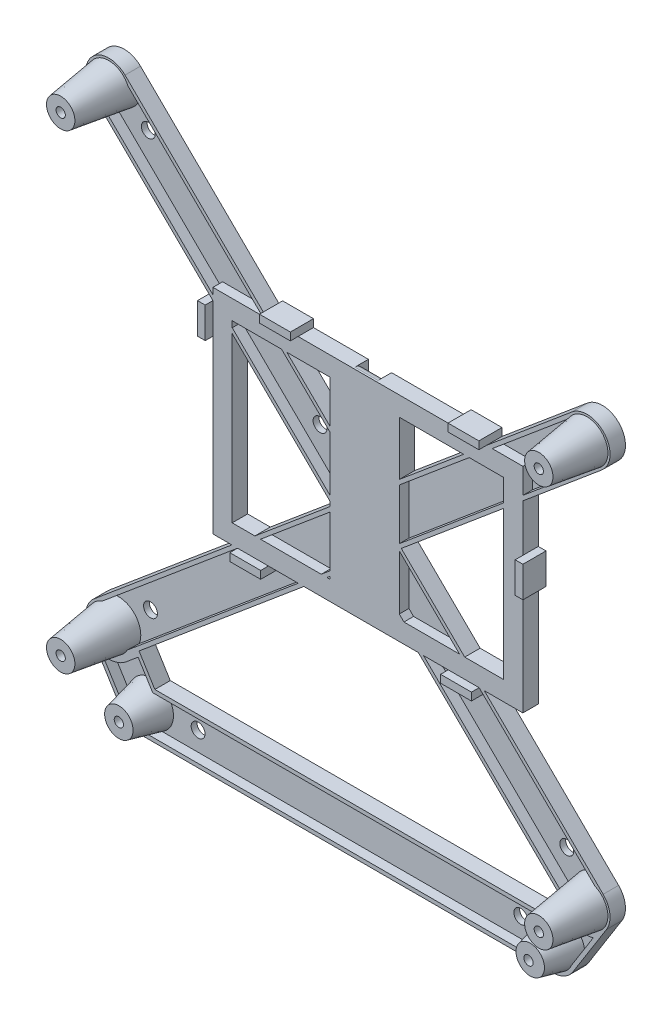
from build123d import *

# Parameters (mm, degrees)
X_BASE_DEPTH                   = 1.905
DRIVE_BASE_DEPTH               = 3.175
SKETCH13_W                     = 102.1
SKETCH13_H                     = 70.358
SKETCH13_W_2                   = 89.4
SKETCH13_H_2                   = 57.658
BOSS_EXTRUDE8_DEPTH            = 5.08
SKETCH14_W                     = 10.16
SKETCH14_H                     = 2.54
SKETCH14_W_2                   = 2.54
SKETCH14_H_2                   = 10.16
DRIVE_TABS_DEPTH               = 7.62
SKETCH15_W                     = 7.62
SKETCH15_H                     = 70.358
TIEDOWN_BASE_DEPTH             = 5.08
SKETCH15_3_W                   = 7.62
SKETCH15_3_H                   = 70.358
TIEDOWN_GROOVE_DEPTH           = 1.905
SKETCH16_R                     = 7.62
ITX_SCREW_BOSSES_DEPTH         = 20.93
ITX_SCREW_BOSSES_TAPER         = 8
SKETCH17_R                     = 2.286
MOUNTING_HOLES_DEPTH           = 2.905
POWER_BOARD_ARM_DEPTH          = 1.905
POWER_BOARD_EDGES_DEPTH        = 3.175
SKETCH18_R                     = 1.524
ITX_SCREW_HOLES_DEPTH          = 21.93
SKETCH21_R                     = 7.62
POWER_BOSSES_DEPTH             = 12.7
POWER_BOSSES_TAPER             = 13
SKETCH22_R                     = 1.524
POWER_SCREW_HOLES_DEPTH        = 13.7
SKETCH23_R                     = 2.286
POWER_MOUNTING_HOLES_DEPTH     = 2.905
FILLET1_R                      = 2.54
SKETCH24_R                     = 2.286
ADDITIONAL_MOUNTING_HOLE_DEPTH = 12.7


with BuildPart() as part:
    # Sketch11 → X Base (new body)
    with BuildSketch(Plane.XY):
        with BuildLine():
            Line((169.174170928, 10.331780288), (102.683212564, 75.750303839))
            Line((102.683212564, 75.750303839), (90.952862043, 65.911945338))
            Line((90.952862043, 65.911945338), (158.485829072, -0.531780288))
            ThreePointArc((158.485829072, -0.531780288), (169.261780288, -0.444170928), (169.174170928, 10.331780288))
        make_face()
        Polygon((102.683212564, 75.750303839), (91.769792824, 86.48770068), (80.039442303, 76.649342179), (90.952862043, 65.911945338), align=None)
        with BuildLine():
            Line((90.952862043, 65.911945338), (80.039442303, 76.649342179))
            Line((80.039442303, 76.649342179), (1.453294564, 10.738379559))
            ThreePointArc((1.453294564, 10.738379559), (0.511620441, 0.003294564), (11.246705436, -0.938379559))
            Line((11.246705436, -0.938379559), (90.952862043, 65.911945338))
        make_face()
        with BuildLine():
            Line((158.933294564, 142.818379559), (91.769792824, 86.48770068))
            Line((91.769792824, 86.48770068), (102.683212564, 75.750303839))
            Line((102.683212564, 75.750303839), (168.726705436, 131.141620441))
            ThreePointArc((168.726705436, 131.141620441), (169.668379559, 141.876705436), (158.933294564, 142.818379559))
        make_face()
        with BuildLine():
            Line((91.769792824, 86.48770068), (11.694170928, 165.271780288))
            ThreePointArc((11.694170928, 165.271780288), (0.918219712, 165.184170928), (1.005829072, 154.408219712))
            Line((1.005829072, 154.408219712), (80.039442303, 76.649342179))
            Line((80.039442303, 76.649342179), (91.769792824, 86.48770068))
        make_face()
    extrude(amount=X_BASE_DEPTH)

    # Sketch12 → Drive Base (add)
    with BuildSketch(Plane.XY.offset(1.905)):
        with BuildLine():
            Line((90.952862043, 65.911945338), (158.485829072, -0.531780288))
            ThreePointArc((158.485829072, -0.531780288), (169.261780288, -0.444170928), (169.174170928, 10.331780288))
            Line((169.174170928, 10.331780288), (102.683212564, 75.750303839))
            Line((102.683212564, 75.750303839), (168.726705436, 131.141620441))
            ThreePointArc((168.726705436, 131.141620441), (169.668379559, 141.876705436), (158.933294564, 142.818379559))
            Line((158.933294564, 142.818379559), (91.769792824, 86.48770068))
            Line((91.769792824, 86.48770068), (11.694170928, 165.271780288))
            ThreePointArc((11.694170928, 165.271780288), (0.918219712, 165.184170928), (1.005829072, 154.408219712))
            Line((1.005829072, 154.408219712), (80.039442303, 76.649342179))
            Line((80.039442303, 76.649342179), (1.453294564, 10.738379559))
            ThreePointArc((1.453294564, 10.738379559), (0.511620441, 0.003294564), (11.246705436, -0.938379559))
            Line((11.246705436, -0.938379559), (90.952862043, 65.911945338))
        make_face()
        with BuildLine():
            Line((91.017187302, 67.532083553), (159.327430793, 0.323618183))
            ThreePointArc((159.327430793, 0.323618183), (168.406381817, 0.397430793), (168.332569207, 9.476381817))
            Line((168.332569207, 9.476381817), (100.900238528, 75.821094259))
            Line((100.900238528, 75.821094259), (167.955570722, 132.061050293))
            ThreePointArc((167.955570722, 132.061050293), (168.748949707, 141.105570722), (159.704429278, 141.898949707))
            Line((159.704429278, 141.898949707), (91.705467566, 84.867562464))
            Line((91.705467566, 84.867562464), (10.852569207, 164.416381817))
            ThreePointArc((10.852569207, 164.416381817), (1.773618183, 164.342569207), (1.847430793, 155.263618183))
            Line((1.847430793, 155.263618183), (81.822416339, 76.578551758))
            Line((81.822416339, 76.578551758), (2.224429278, 9.818949707))
            ThreePointArc((2.224429278, 9.818949707), (1.431050293, 0.774429278), (10.475570722, -0.018949707))
            Line((10.475570722, -0.018949707), (91.017187302, 67.532083553))
        make_face(mode=Mode.SUBTRACT)
    extrude(amount=DRIVE_BASE_DEPTH)

    # Sketch13 → Boss-Extrude8 (add)
    with BuildSketch(Plane.XY):
        with Locations((91.69, 84.021)):
            Rectangle(SKETCH13_W, SKETCH13_H)
        with Locations((91.69, 84.021)):
            Rectangle(SKETCH13_W_2, SKETCH13_H_2, mode=Mode.SUBTRACT)
    extrude(amount=BOSS_EXTRUDE8_DEPTH)

    # Sketch14 → Drive Tabs (add)
    with BuildSketch(Plane.XY):
        with Locations((63.601226302, 120.47)):
            Rectangle(SKETCH14_W, SKETCH14_H)
        with Locations((125.692918936, 120.47)):
            Rectangle(SKETCH14_W, SKETCH14_H)
        with Locations((53.83191232, 47.572)):
            Rectangle(SKETCH14_W, SKETCH14_H)
        with Locations((123.241613021, 47.572)):
            Rectangle(SKETCH14_W, SKETCH14_H)
        with Locations((144.01, 88.72)):
            Rectangle(SKETCH14_W_2, SKETCH14_H_2)
        with Locations((39.37, 110.333309606)):
            Rectangle(SKETCH14_W_2, SKETCH14_H_2)
    extrude(amount=DRIVE_TABS_DEPTH)

    # Sketch15 → Tiedown Base (add)
    with BuildSketch(Plane.XY):
        with Locations((82.971905785, 84.021)):
            Rectangle(SKETCH15_W, SKETCH15_H)
        with Locations((98.211905785, 84.021)):
            Rectangle(SKETCH15_W, SKETCH15_H)
        with Locations((90.591905785, 84.021)):
            Rectangle(SKETCH15_W, SKETCH15_H)
    extrude(amount=TIEDOWN_BASE_DEPTH)

    # Sketch15_3 → Tiedown Groove (cut)
    with BuildSketch(Plane.XY):
        with Locations((90.591905785, 84.021)):
            Rectangle(SKETCH15_3_W, SKETCH15_3_H)
    extrude(amount=TIEDOWN_GROOVE_DEPTH, mode=Mode.SUBTRACT)

    # Sketch16 → ITX Screw Bosses (add)
    with BuildSketch(Plane.XY):
        with Locations((6.35, 4.9)):
            Circle(SKETCH16_R)
        with Locations((6.35, 159.84)):
            Circle(SKETCH16_R)
        with Locations((163.83, 136.98)):
            Circle(SKETCH16_R)
        with Locations((163.83, 4.9)):
            Circle(SKETCH16_R)
    extrude(amount=ITX_SCREW_BOSSES_DEPTH, taper=ITX_SCREW_BOSSES_TAPER)

    # Sketch17 → Mounting Holes (cut, through all)
    with BuildSketch(Plane.XY.offset(1.905)):
        with Locations((16.167315371, 150.181028426)):
            Circle(SKETCH17_R)
        with Locations((16.902196581, 13.750229391)):
            Circle(SKETCH17_R)
        with Locations((154.012684629, 14.558971574)):
            Circle(SKETCH17_R)
        with Locations((153.277803419, 128.129770609)):
            Circle(SKETCH17_R)
    extrude(amount=-MOUNTING_HOLES_DEPTH, mode=Mode.SUBTRACT)

    # Sketch19 → Power Board Arm (add)
    with BuildSketch(Plane.XY):
        with BuildLine():
            ThreePointArc((10.797389556, -16.717937231), (10.613130663, -8.995427265), (17.272, -5.08))
            Line((17.272, -5.08), (21.511284901, -5.08))
            Line((21.511284901, -5.08), (12.824610444, 8.917937231))
            ThreePointArc((12.824610444, 8.917937231), (2.332062769, 11.374610444), (-0.124610444, 0.882062769))
            Line((-0.124610444, 0.882062769), (10.797389556, -16.717937231))
        make_face()
        with BuildLine():
            Line((21.511284901, -5.08), (17.272, -5.08))
            ThreePointArc((17.272, -5.08), (10.613130663, -8.995427265), (10.797389556, -16.717937231))
            ThreePointArc((10.797389556, -16.717937231), (13.567427265, -19.358869337), (17.272, -20.32))
            ThreePointArc((17.272, -20.32), (23.930869337, -16.404572735), (23.746610444, -8.682062769))
            Line((23.746610444, -8.682062769), (21.511284901, -5.08))
        make_face()
        with BuildLine():
            Line((148.560410145, -5.08), (21.511284901, -5.08))
            Line((21.511284901, -5.08), (23.746610444, -8.682062769))
            ThreePointArc((23.746610444, -8.682062769), (23.930869337, -16.404572735), (17.272, -20.32))
            Line((17.272, -20.32), (152.772, -20.32))
            ThreePointArc((152.772, -20.32), (146.102858559, -16.386048351), (146.319827347, -8.64612925))
            Line((146.319827347, -8.64612925), (148.560410145, -5.08))
        make_face()
        with BuildLine():
            Line((157.377827347, 8.95387075), (148.560410145, -5.08))
            Line((148.560410145, -5.08), (152.772, -5.08))
            ThreePointArc((152.772, -5.08), (159.441141441, -9.013951649), (159.224172653, -16.75387075))
            Line((159.224172653, -16.75387075), (170.282172653, 0.84612925))
            ThreePointArc((170.282172653, 0.84612925), (167.88387075, 11.352172653), (157.377827347, 8.95387075))
        make_face()
        with BuildLine():
            Line((152.772, -5.08), (148.560410145, -5.08))
            Line((148.560410145, -5.08), (146.319827347, -8.64612925))
            ThreePointArc((146.319827347, -8.64612925), (146.102858559, -16.386048351), (152.772, -20.32))
            ThreePointArc((152.772, -20.32), (156.458048351, -19.369141441), (159.224172653, -16.75387075))
            ThreePointArc((159.224172653, -16.75387075), (159.441141441, -9.013951649), (152.772, -5.08))
        make_face()
    extrude(amount=POWER_BOARD_ARM_DEPTH)

    # Sketch20 → Power Board Edges (add)
    with BuildSketch(Plane.XY.offset(1.905)):
        with BuildLine():
            Line((158.485829072, -0.531780288), (154.11803731, 3.765563221))
            Line((154.11803731, 3.765563221), (148.560410145, -5.08))
            Line((148.560410145, -5.08), (21.511284901, -5.08))
            Line((21.511284901, -5.08), (16.307238366, 3.305938383))
            Line((16.307238366, 3.305938383), (11.246705436, -0.938379559))
            ThreePointArc((11.246705436, -0.938379559), (5.145446713, -2.624191078), (-0.124610444, 0.882062769))
            Line((-0.124610444, 0.882062769), (10.797389556, -16.717937231))
            ThreePointArc((10.797389556, -16.717937231), (13.567427265, -19.358869337), (17.272, -20.32))
            Line((17.272, -20.32), (152.772, -20.32))
            ThreePointArc((152.772, -20.32), (156.458048351, -19.369141441), (159.224172653, -16.75387075))
            Line((159.224172653, -16.75387075), (170.282172653, 0.84612925))
            ThreePointArc((170.282172653, 0.84612925), (164.714067661, -2.66854176), (158.485829072, -0.531780288))
        make_face()
        with BuildLine():
            Line((157.595133917, -1.437077002), (154.353167999, 1.752599143))
            Line((154.353167999, 1.752599143), (149.262341788, -6.35))
            Line((149.262341788, -6.35), (20.804737418, -6.35))
            Line((20.804737418, -6.35), (16.000724642, 1.39131339))
            Line((16.000724642, 1.39131339), (12.062823009, -1.911442818))
            ThreePointArc((12.062823009, -1.911442818), (8.36679015, -3.758213297), (4.235123308, -3.734778317))
            Line((4.235123308, -3.734778317), (11.876491296, -16.048281026))
            ThreePointArc((11.876491296, -16.048281026), (14.184856054, -18.249057781), (17.272, -19.05))
            Line((17.272, -19.05), (152.772, -19.05))
            ThreePointArc((152.772, -19.05), (155.843706959, -18.257617867), (158.148810544, -16.078225625))
            Line((158.148810544, -16.078225625), (165.896838937, -3.746402536))
            ThreePointArc((165.896838937, -3.746402536), (161.447488998, -3.664796631), (157.595133917, -1.437077002))
        make_face(mode=Mode.SUBTRACT)
    extrude(amount=POWER_BOARD_EDGES_DEPTH)

    # Sketch18 → ITX Screw Holes (cut, through all)
    with BuildSketch(Plane.XY.offset(20.93)):
        with Locations((6.35, 4.9)):
            Circle(SKETCH18_R)
        with Locations((6.35, 159.84)):
            Circle(SKETCH18_R)
        with Locations((163.83, 136.98)):
            Circle(SKETCH18_R)
        with Locations((163.83, 4.9)):
            Circle(SKETCH18_R)
    extrude(amount=-ITX_SCREW_HOLES_DEPTH, mode=Mode.SUBTRACT)

    # Sketch21 → Power Bosses (add)
    with BuildSketch(Plane.XY):
        with Locations((17.272, -12.7)):
            Circle(SKETCH21_R)
        with Locations((152.772, -12.7)):
            Circle(SKETCH21_R)
    extrude(amount=POWER_BOSSES_DEPTH, taper=POWER_BOSSES_TAPER)

    # Sketch22 → Power Screw Holes (cut, through all)
    with BuildSketch(Plane.XY.offset(12.7)):
        with Locations((17.272, -12.7)):
            Circle(SKETCH22_R)
        with Locations((152.207933682, -13.19458251)):
            Circle(SKETCH22_R)
    extrude(amount=-POWER_SCREW_HOLES_DEPTH, mode=Mode.SUBTRACT)

    # Sketch23 → Power Mounting Holes (cut, through all)
    with BuildSketch(Plane.XY.offset(1.905)):
        with Locations((138.869803904, -12.7)):
            Circle(SKETCH23_R)
        with Locations((32.580196096, -12.7)):
            Circle(SKETCH23_R)
    extrude(amount=-POWER_MOUNTING_HOLES_DEPTH, mode=Mode.SUBTRACT)

    # Fillet1
    fillet1_edges = [part.edges().sort_by_distance(p)[0] for p in [
        (90.591905785, 119.2, 1.905),
        (90.591905785, 48.842, 1.905),
    ]]
    fillet(fillet1_edges, radius=FILLET1_R)

    # Sketch24 → Additional Mounting Hole (cut)
    with BuildSketch(Plane.XY.offset(1.905)):
        with Locations((72.741905785, 94.518931405)):
            Circle(SKETCH24_R)
    extrude(amount=-ADDITIONAL_MOUNTING_HOLE_DEPTH, mode=Mode.SUBTRACT)


solid = part.part
